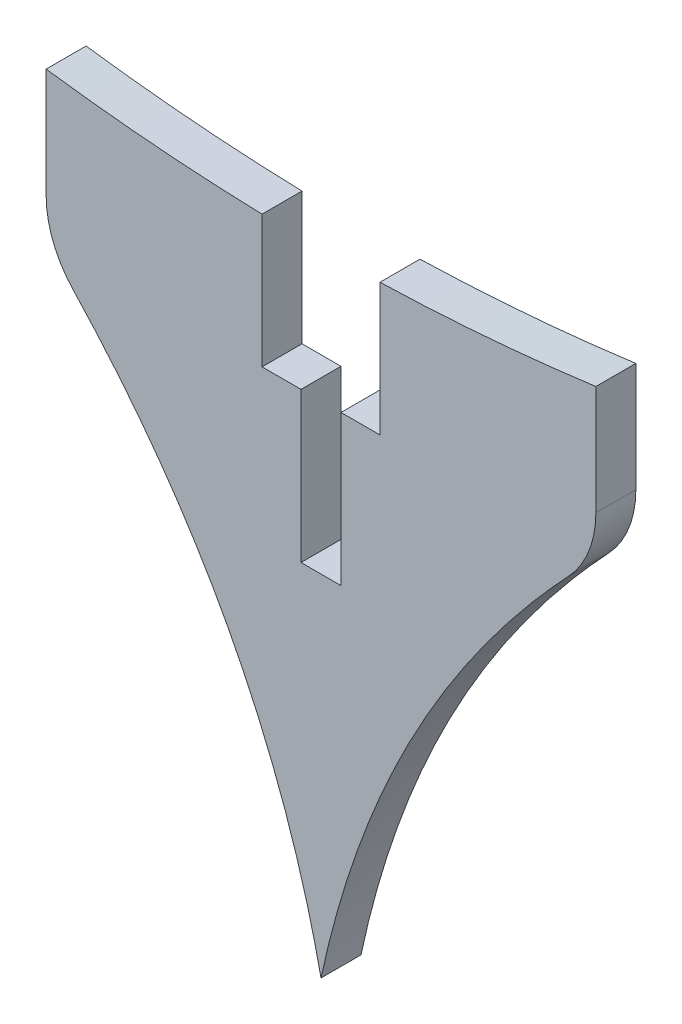
from build123d import *

# Parameters (mm, degrees)
BOSS_EXTRU_1_DEPTH = 4
CONG_1_R           = 10


with BuildPart() as part:
    # Esquisse1 → Boss.-Extru.1 (new body)
    with BuildSketch(Plane.XY):
        with BuildLine():
            Line((-27.5, 32.5), (-27.5, 17.5))
            add(Edge.make_bspline(
                [(-27.5, 17.5), (-6.129432255, -3.700842112), (0, -32.5)],
                knots=[0, 0, 0, 1, 1, 1], degree=2))
            add(Edge.make_bspline(
                [(27.5, 17.5), (6.129432255, -3.700842112), (0, -32.5)],
                knots=[0, 0, 0, 1, 1, 1], degree=2))
            Line((27.5, 17.5), (27.5, 32.5))
            ThreePointArc((27.5, 32.5), (16.723379615, 31.330378268), (5.9, 30.732034209))
            Line((5.9, 30.732034209), (5.9, 17.5))
            Line((5.9, 17.5), (2, 17.5))
            Line((2, 17.5), (2, 2.5))
            Line((2, 2.5), (-2, 2.5))
            Line((-2, 2.5), (-2, 17.5))
            Line((-2, 17.5), (-5.9, 17.5))
            Line((-5.9, 17.5), (-5.9, 30.732034209))
            ThreePointArc((-5.9, 30.732034209), (-16.723379615, 31.330378268), (-27.5, 32.5))
        make_face()
    extrude(amount=BOSS_EXTRU_1_DEPTH)

    # Congé1
    cong_1_edges = [part.edges().sort_by_distance(p)[0] for p in [
        (-27.5, 17.5, 2),
        (27.5, 17.5, 2),
    ]]
    fillet(cong_1_edges, radius=CONG_1_R)


solid = part.part
